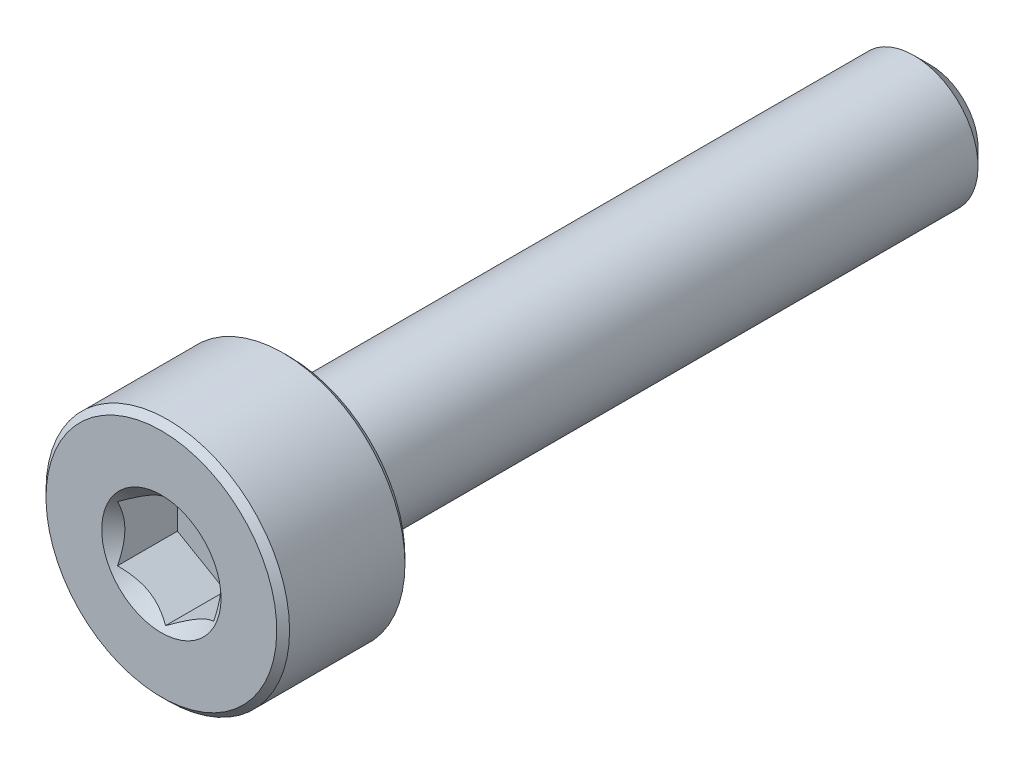
from build123d import *

# Parameters (mm, degrees)
CUT_EXTRUDE1_DEPTH = 1
SKETCH4_R          = 0.930977309
CUT_EXTRUDE2_DEPTH = 1
CUT_EXTRUDE2_DRAFT = -45


with BuildPart() as part:
    # Sketch2 → Revolve1 (revolve)
    with BuildSketch(Plane(origin=(0, 0, 0), x_dir=(0, 0, -1), z_dir=(1, 0, 0))):
        with BuildLine():
            Line((-6, 0), (-6, 1.8))
            Line((-6, 1.8), (-5.9, 1.9))
            Line((-5.9, 1.9), (-4.1, 1.9))
            Line((-4.1, 1.9), (-4, 1.8))
            Line((-4, 1.8), (-4, 1.1))
            ThreePointArc((-4, 1.1), (-3.970710678, 1.029289322), (-3.9, 1))
            Line((-3.9, 1), (5.740192379, 1))
            Line((5.740192379, 1), (6, 0.740192379))
            Line((6, 0.740192379), (6, 0))
            Line((6, 0), (-6, 0))
        make_face()
    revolve(axis=Axis((0, 0, -6), (0, 0, 1)))

    # Sketch3 → Cut-Extrude1 (cut)
    with BuildSketch(Plane.XY.offset(6)):
        Polygon((0.75, -0.433012702), (0.75, 0.433012702), (0, 0.866025404), (-0.75, 0.433012702), (-0.75, -0.433012702), (0, -0.866025404), align=None)
    extrude(amount=-CUT_EXTRUDE1_DEPTH, mode=Mode.SUBTRACT)


with BuildPart() as cut_extrude2_tool:
    # Sketch4 → Cut-Extrude2 (with draft: the straight prism first)
    with BuildSketch(Plane.XY.offset(6)):
        Circle(SKETCH4_R)
    extrude(amount=-CUT_EXTRUDE2_DEPTH)
    # Cut-Extrude2: the draft: its side faces are tilted about the plane it starts from
    cut_extrude2_sides = [cut_extrude2_tool.faces().sort_by_distance(p)[0] for p in [
        (-0.930977309, 0, 5.5),
    ]]
    draft(cut_extrude2_sides, Plane.XY.offset(6), CUT_EXTRUDE2_DRAFT)


with BuildPart() as part_1:
    add(part.part)

    # Cut-Extrude2: cut by cut_extrude2_tool
    add(cut_extrude2_tool.part, mode=Mode.SUBTRACT)


solid = part_1.part
